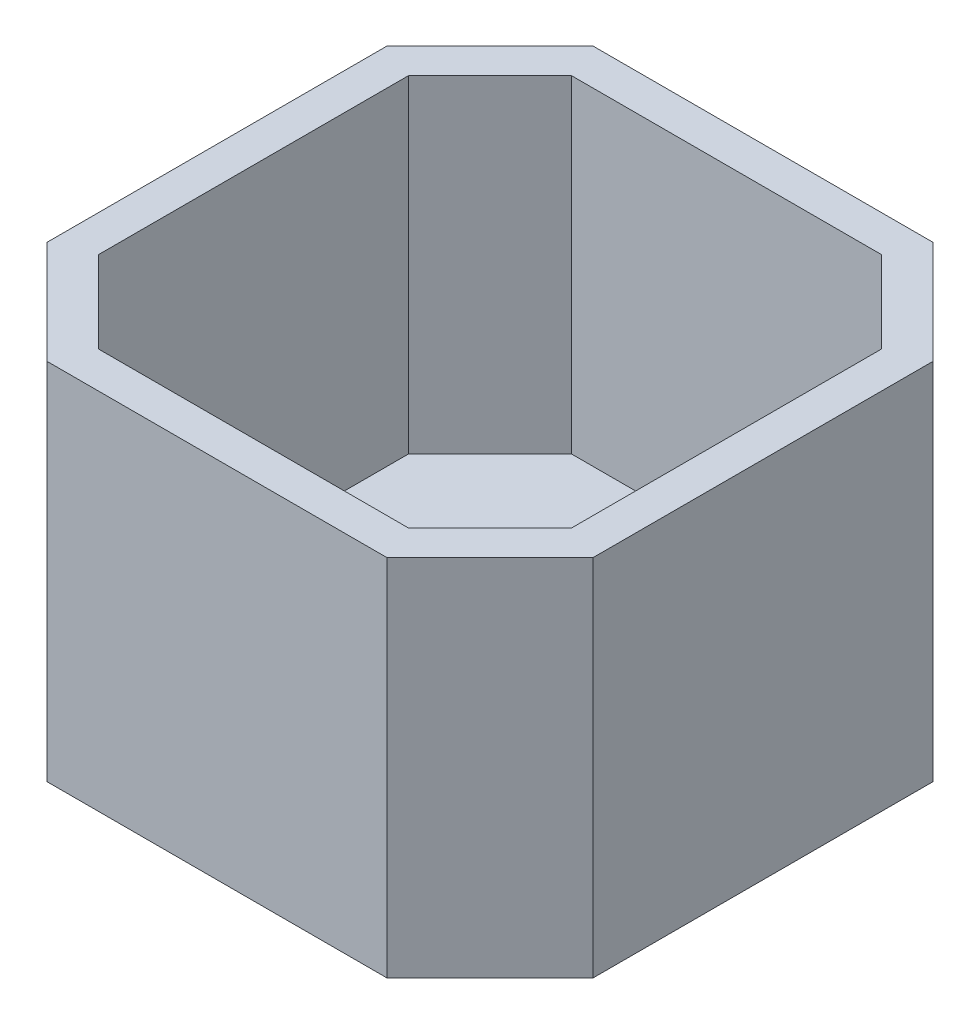
from build123d import *

# Parameters (mm, degrees)
BOSS_EXTRUDE1_DEPTH = 20
CUT_EXTRUDE1_DEPTH  = 18


with BuildPart() as part:
    # Sketch1 → Boss-Extrude1 (new body)
    with BuildSketch(Plane(origin=(0, 0, 0), x_dir=(1, 0, 0), z_dir=(0, 1, 0))):
        Polygon((-9.343145751, 15), (-15, 9.343145751), (-15, -9.343145751), (-9.343145751, -15), (9.343145751, -15), (15, -9.343145751), (15, 9.343145751), (9.343145751, 15), align=None)
    extrude(amount=BOSS_EXTRUDE1_DEPTH)

    # Sketch2 → Cut-Extrude1 (cut)
    with BuildSketch(Plane(origin=(0, 20, 0), x_dir=(1, 0, 0), z_dir=(0, 1, 0))):
        Polygon((-8.514718626, 13), (-13, 8.514718626), (-13, -8.514718626), (-8.514718626, -13), (8.514718626, -13), (13, -8.514718626), (13, 8.514718626), (8.514718626, 13), align=None)
    extrude(amount=-CUT_EXTRUDE1_DEPTH, mode=Mode.SUBTRACT)


solid = part.part
